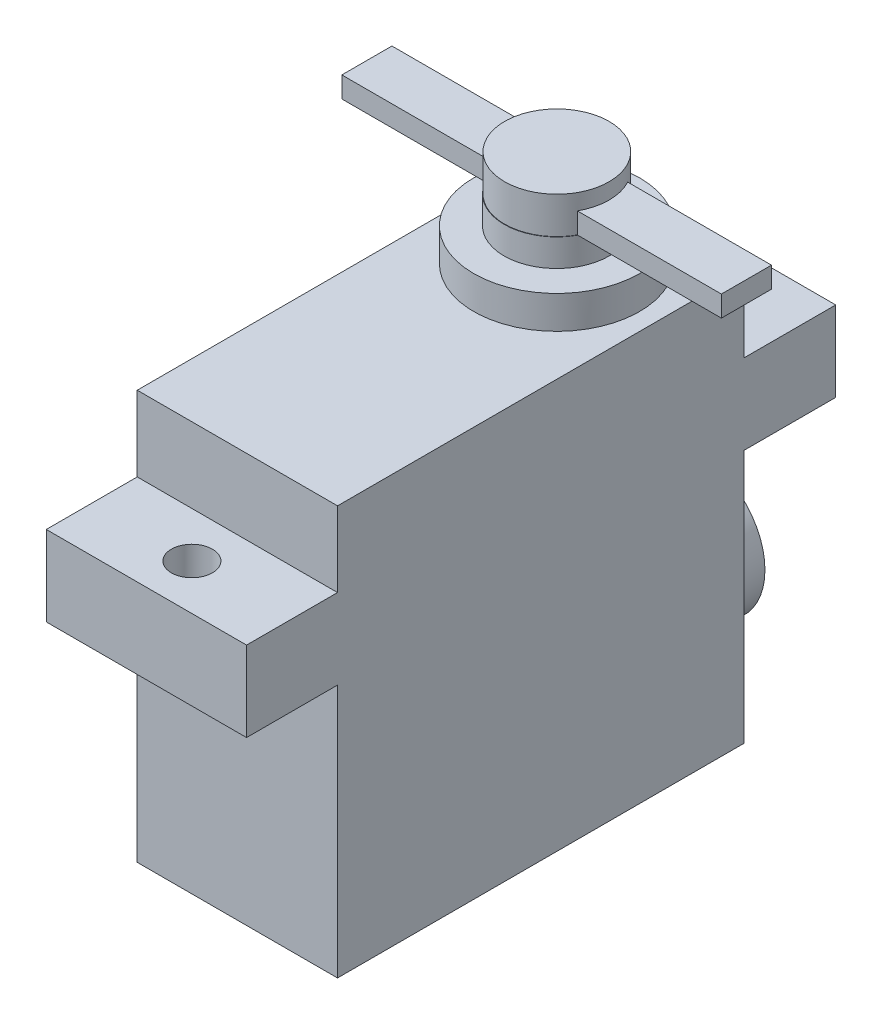
from build123d import *

# Parameters (mm, degrees)
SKETCH1_W                = 15.24
SKETCH1_H                = 30.9118
BOSS_EXTRUDE1_DEPTH      = 31.115
SKETCH2_W                = 15.24
SKETCH2_H                = 6.096
BOSS_EXTRUDE2_DEPTH      = 6.9215
BOSS_EXTRUDE2_DEPTH_BACK = 37.9095
SKETCH3_R                = 5.2705
BOSS_EXTRUDE3_DEPTH      = 3.9624
SKETCH4_R                = 6.3119
BOSS_EXTRUDE4_DEPTH      = 2.5019
CUT_EXTRUDE1_REACH       = 27.4
SKETCH8_R                = 1.5621
CUT_EXTRUDE2_REACH       = 27.4
SKETCH9_R                = 1.5621
SKETCH10_R               = 3.99415
BOSS_EXTRUDE5_DEPTH      = 2.0828
SKETCH11_W               = 14.4399
SKETCH11_H               = 3.81
BOSS_EXTRUDE6_DEPTH      = 1.5875
SKETCH12_R               = 3.976792142
BOSS_EXTRUDE7_DEPTH      = 2.794


with BuildPart() as part:
    # Sketch1 → Boss-Extrude1 (new body)
    with BuildSketch(Plane(origin=(0, 0, 0), x_dir=(1, 0, 0), z_dir=(0, 1, 0))):
        with Locations((7.62, 15.4559)):
            Rectangle(SKETCH1_W, SKETCH1_H)
    extrude(amount=BOSS_EXTRUDE1_DEPTH)

    # Sketch2 → Boss-Extrude2 (add, two sides)
    with BuildSketch(Plane.XY) as boss_extrude2_sk:
        with Locations((7.62, 22.352)):
            Rectangle(SKETCH2_W, SKETCH2_H)
    extrude(amount=BOSS_EXTRUDE2_DEPTH)
    extrude(boss_extrude2_sk.sketch, amount=-BOSS_EXTRUDE2_DEPTH_BACK)

    # Sketch3 → Boss-Extrude3 (add)
    with BuildSketch(Plane(origin=(0, 0, -30.9118), x_dir=(-1, 0, 0), z_dir=(0, 0, -1))):
        with Locations((-7.62, 8.2804)):
            Circle(SKETCH3_R)
    extrude(amount=BOSS_EXTRUDE3_DEPTH)

    # Sketch4 → Boss-Extrude4 (add)
    with BuildSketch(Plane(origin=(0, 31.115, 0), x_dir=(1, 0, 0), z_dir=(0, 1, 0))):
        with Locations((7.62, 24.2951)):
            Circle(SKETCH4_R)
    extrude(amount=BOSS_EXTRUDE4_DEPTH)

    # Sketch8 → Cut-Extrude1 (cut, up to next)
    with BuildSketch(Plane(origin=(0, 25.4, 0), x_dir=(1, 0, 0), z_dir=(0, 1, 0)), mode=Mode.PRIVATE) as cut_extrude1_sk1:
        with Locations((7.62, -3.46075)):
            Circle(SKETCH8_R)
    cut_extrude1_tool1 = extrude(cut_extrude1_sk1.sketch, amount=-CUT_EXTRUDE1_REACH, mode=Mode.PRIVATE) & part.part
    add(cut_extrude1_tool1.solids().sort_by_distance((7.62, 25.4, 3.46075))[0], mode=Mode.SUBTRACT)

    # Sketch9 → Cut-Extrude2 (cut, up to next)
    with BuildSketch(Plane(origin=(0, 25.4, 0), x_dir=(1, 0, 0), z_dir=(0, 1, 0)), mode=Mode.PRIVATE) as cut_extrude2_sk1:
        with Locations((7.62, 34.41065)):
            Circle(SKETCH9_R)
    cut_extrude2_tool1 = extrude(cut_extrude2_sk1.sketch, amount=-CUT_EXTRUDE2_REACH, mode=Mode.PRIVATE) & part.part
    add(cut_extrude2_tool1.solids().sort_by_distance((7.62, 25.4, -34.41065))[0], mode=Mode.SUBTRACT)

    # Sketch10 → Boss-Extrude5 (add)
    with BuildSketch(Plane(origin=(0, 33.6169, 0), x_dir=(1, 0, 0), z_dir=(0, 1, 0))):
        with Locations((7.62, 24.2951)):
            Circle(SKETCH10_R)
    extrude(amount=BOSS_EXTRUDE5_DEPTH)

    # Sketch11 → Boss-Extrude6 (add)
    with BuildSketch(Plane(origin=(0, 35.6997, 0), x_dir=(1, 0, 0), z_dir=(0, 1, 0))):
        with Locations((14.83995, 24.2951)):
            Rectangle(SKETCH11_W, SKETCH11_H)
        with Locations((0.40005, 24.2951)):
            Rectangle(SKETCH11_W, SKETCH11_H)
    extrude(amount=BOSS_EXTRUDE6_DEPTH)

    # Sketch12 → Boss-Extrude7 (add)
    with BuildSketch(Plane(origin=(0, 35.6997, 0), x_dir=(1, 0, 0), z_dir=(0, 1, 0))):
        with Locations((7.619570472, 24.312452542)):
            Circle(SKETCH12_R)
    extrude(amount=BOSS_EXTRUDE7_DEPTH)


solid = part.part
